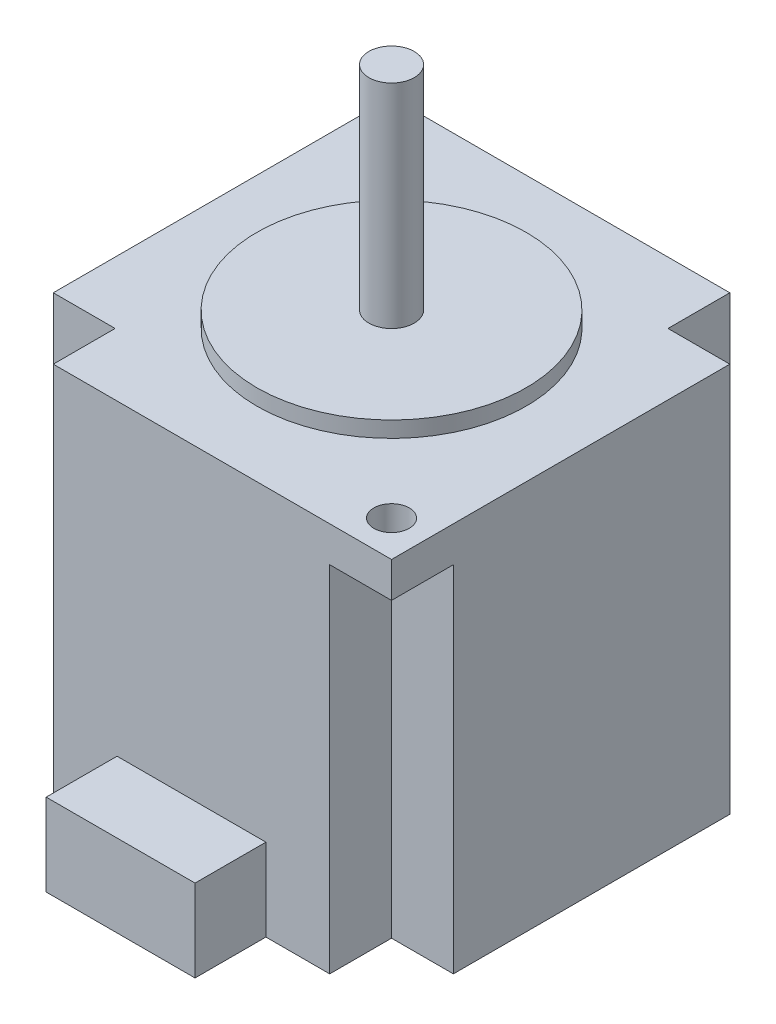
from build123d import *

# Parameters (mm, degrees)
SKETCH1_W           = 56.45
SKETCH1_H           = 56.45
BOSS_EXTRUDE1_DEPTH = 55
SKETCH2_R           = 19
BOSS_EXTRUDE2_DEPTH = 2.25
SKETCH3_R           = 3.2
BOSS_EXTRUDE3_DEPTH = 30
SKETCH4_W           = 8.725
SKETCH4_H           = 8.725
CUT_EXTRUDE1_DEPTH  = 55
SKETCH4_3_W         = 8.725
SKETCH4_3_H         = 8.725
CUT_EXTRUDE2_DEPTH  = 50
BOSS_EXTRUDE4_DEPTH = 11.6
SKETCH6_R           = 2.5
CUT_EXTRUDE3_DEPTH  = 5
SKETCH7_R           = 4.5
CUT_EXTRUDE4_DEPTH  = 2.35


with BuildPart() as part:
    # Sketch1 → Boss-Extrude1 (new body)
    with BuildSketch(Plane(origin=(0, 0, 0), x_dir=(1, 0, 0), z_dir=(0, 1, 0))):
        Rectangle(SKETCH1_W, SKETCH1_H)
    extrude(amount=BOSS_EXTRUDE1_DEPTH)

    # Sketch2 → Boss-Extrude2 (add)
    with BuildSketch(Plane(origin=(0, 55, 0), x_dir=(1, 0, 0), z_dir=(0, 1, 0))):
        Circle(SKETCH2_R)
    extrude(amount=BOSS_EXTRUDE2_DEPTH)

    # Sketch3 → Boss-Extrude3 (add)
    with BuildSketch(Plane(origin=(0, 57.25, 0), x_dir=(1, 0, 0), z_dir=(0, 1, 0))):
        Circle(SKETCH3_R)
    extrude(amount=BOSS_EXTRUDE3_DEPTH)

    # Sketch4 → Cut-Extrude1 (cut)
    with BuildSketch(Plane.XZ):
        with Locations((23.8625, -23.8625)):
            Rectangle(SKETCH4_W, SKETCH4_H)
        with Locations((-23.8625, 23.8625)):
            Rectangle(SKETCH4_W, SKETCH4_H)
    extrude(amount=-CUT_EXTRUDE1_DEPTH, mode=Mode.SUBTRACT)

    # Sketch4_3 → Cut-Extrude2 (cut)
    with BuildSketch(Plane.XZ):
        with Locations((23.8625, 23.8625)):
            Rectangle(SKETCH4_3_W, SKETCH4_3_H)
        with Locations((-23.8625, -23.8625)):
            Rectangle(SKETCH4_3_W, SKETCH4_3_H)
    extrude(amount=-CUT_EXTRUDE2_DEPTH, mode=Mode.SUBTRACT)

    # Sketch5 → Boss-Extrude4 (add)
    with BuildSketch(Plane.XZ):
        Polygon((0, 28.225), (10.5, 28.225), (10.5, 38.225), (-10.5, 38.225), (-10.5, 28.225), align=None)
    extrude(amount=-BOSS_EXTRUDE4_DEPTH)

    # Sketch6 → Cut-Extrude3 (cut)
    with BuildSketch(Plane(origin=(0, 55, 0), x_dir=(1, 0, 0), z_dir=(0, 1, 0))):
        with Locations((-23.175, 23.175)):
            Circle(SKETCH6_R)
        with Locations((23.175, -23.175)):
            Circle(SKETCH6_R)
    extrude(amount=-CUT_EXTRUDE3_DEPTH, mode=Mode.SUBTRACT)

    # Sketch7 → Cut-Extrude4 (cut)
    with BuildSketch(Plane.XZ):
        Circle(SKETCH7_R)
    extrude(amount=-CUT_EXTRUDE4_DEPTH, mode=Mode.SUBTRACT)


solid = part.part
